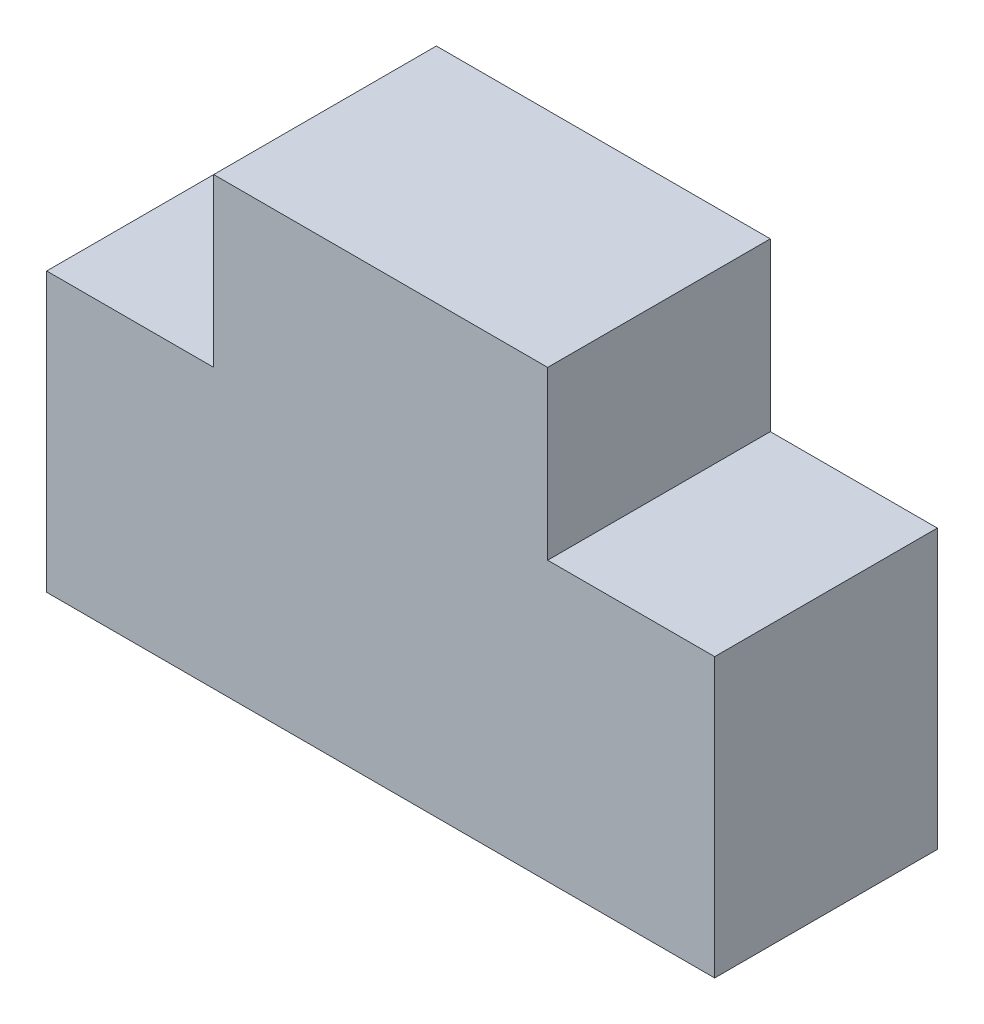
from build123d import *

# Parameters (mm, degrees)
SKETCH1_W           = 76.2
SKETCH1_H           = 50.8
BOSS_EXTRUDE1_DEPTH = 12.7
SKETCH2_W           = 19.05
SKETCH2_H           = 19.05
CUT_EXTRUDE1_DEPTH  = 26.4


with BuildPart() as part:
    # Sketch1 → Boss-Extrude1 (new body, symmetric)
    with BuildSketch(Plane.XY):
        Rectangle(SKETCH1_W, SKETCH1_H)
    extrude(amount=BOSS_EXTRUDE1_DEPTH, both=True)

    # Sketch2 → Cut-Extrude1 (cut, through all)
    with BuildSketch(Plane.XY.offset(12.7)):
        with Locations((-28.575, 15.875)):
            Rectangle(SKETCH2_W, SKETCH2_H)
    cut_extrude1 = extrude(amount=-CUT_EXTRUDE1_DEPTH, mode=Mode.SUBTRACT)

    # Mirror1: Cut-Extrude1 across plane
    add(cut_extrude1.mirror(Plane(origin=(0, 0, 0), x_dir=(0, 0, 1), z_dir=(1, 0, 0))), mode=Mode.SUBTRACT)


solid = part.part
